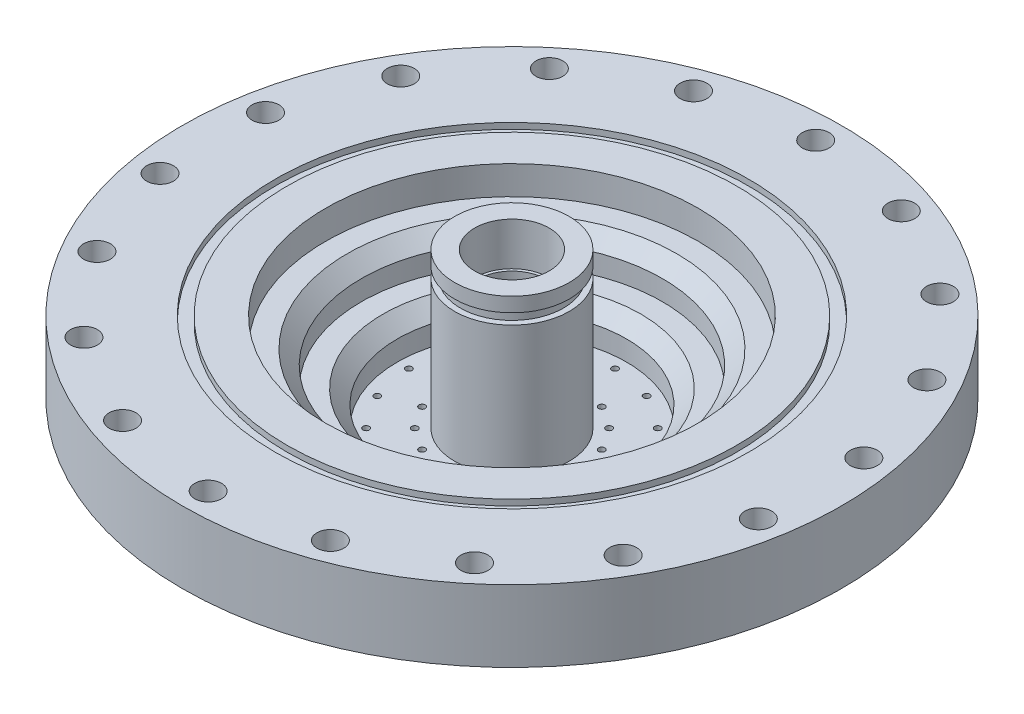
from build123d import *

# Parameters (mm, degrees)
SKETCH1_R           = 38.1
BOSS_EXTRUDE1_DEPTH = 4.445
SKETCH2_R           = 28.575
SKETCH2_R_2         = 7.62
BOSS_EXTRUDE2_DEPTH = 5.08
SKETCH4_R           = 38.1
SKETCH4_R_2         = 7.62
BOSS_EXTRUDE3_DEPTH = 25.4
SKETCH5_R           = 73.025
SKETCH5_R_2         = 38.1
BOSS_EXTRUDE4_DEPTH = 19.05
SKETCH6_R           = 41.275
SKETCH6_R_2         = 12.7
CUT_EXTRUDE1_DEPTH  = 9.525
SKETCH7_R           = 33.3375
SKETCH7_R_2         = 12.7
CUT_EXTRUDE2_DEPTH  = 7.62
SKETCH8_R           = 25.4
SKETCH8_R_2         = 12.7
CUT_EXTRUDE3_DEPTH  = 7.62
SKETCH10_R          = 12.7
SKETCH10_R_2        = 8.255
BOSS_EXTRUDE5_DEPTH = 9.525
CHAMFER1_SIZE       = 3.175
SKETCH12_R          = 0.6985
CUT_EXTRUDE5_DEPTH  = 10.16
CUT_EXTRUDE6_START  = 8.411991
SKETCH14_R          = 0.508
CUT_EXTRUDE6_DEPTH  = 5.719232
CUT_EXTRUDE7_START  = 8.411991
SKETCH15_R          = 0.508
CUT_EXTRUDE7_DEPTH  = 5.719232
CIRPATTERN2_COUNT   = 16
SKETCH16_W          = 1.27
SKETCH16_H          = 2.3622
SKETCH17_R          = 2.97688
CUT_EXTRUDE8_DEPTH  = 35.925000419
CIRPATTERN3_COUNT   = 18
SKETCH20_R          = 86.430986252
SKETCH20_R_2        = 37.221288793
CUT_EXTRUDE11_DEPTH = 3.175
SKETCH18_R          = 52.4383
SKETCH18_R_2        = 49.7967
CUT_EXTRUDE9_DEPTH  = 1.3208
SKETCH19_R          = 0.79375
CUT_EXTRUDE10_DEPTH = 86.868315867
CIRPATTERN4_COUNT   = 16
SKETCH21_W          = 2.4892
SKETCH21_H          = 2.3622


with BuildPart() as part:
    # Sketch1 → Boss-Extrude1 (new body)
    with BuildSketch(Plane(origin=(0, 0, 0), x_dir=(1, 0, 0), z_dir=(0, 1, 0))):
        Circle(SKETCH1_R)
    extrude(amount=BOSS_EXTRUDE1_DEPTH)

    # Sketch2 → Boss-Extrude2 (add)
    with BuildSketch(Plane(origin=(0, 4.445, 0), x_dir=(1, 0, 0), z_dir=(0, 1, 0))):
        Circle(SKETCH2_R)
        Circle(SKETCH2_R_2, mode=Mode.SUBTRACT)
    extrude(amount=BOSS_EXTRUDE2_DEPTH)

    # Sketch4 → Boss-Extrude3 (add)
    with BuildSketch(Plane(origin=(0, 9.525, 0), x_dir=(1, 0, 0), z_dir=(0, 1, 0))):
        Circle(SKETCH4_R)
        Circle(SKETCH4_R_2, mode=Mode.SUBTRACT)
    extrude(amount=BOSS_EXTRUDE3_DEPTH)

    # Sketch5 → Boss-Extrude4 (add)
    with BuildSketch(Plane(origin=(0, 34.925, 0), x_dir=(1, 0, 0), z_dir=(0, 1, 0))):
        Circle(SKETCH5_R)
        Circle(SKETCH5_R_2, mode=Mode.SUBTRACT)
    extrude(amount=-BOSS_EXTRUDE4_DEPTH)

    # Sketch6 → Cut-Extrude1 (cut)
    with BuildSketch(Plane(origin=(0, 34.925, 0), x_dir=(1, 0, 0), z_dir=(0, 1, 0))):
        Circle(SKETCH6_R)
        Circle(SKETCH6_R_2, mode=Mode.SUBTRACT)
    extrude(amount=-CUT_EXTRUDE1_DEPTH, mode=Mode.SUBTRACT)

    # Sketch7 → Cut-Extrude2 (cut)
    with BuildSketch(Plane(origin=(0, 25.4, 0), x_dir=(1, 0, 0), z_dir=(0, 1, 0))):
        Circle(SKETCH7_R)
        Circle(SKETCH7_R_2, mode=Mode.SUBTRACT)
    extrude(amount=-CUT_EXTRUDE2_DEPTH, mode=Mode.SUBTRACT)

    # Sketch8 → Cut-Extrude3 (cut)
    with BuildSketch(Plane(origin=(0, 17.78, 0), x_dir=(1, 0, 0), z_dir=(0, 1, 0))):
        Circle(SKETCH8_R)
        Circle(SKETCH8_R_2, mode=Mode.SUBTRACT)
    extrude(amount=-CUT_EXTRUDE3_DEPTH, mode=Mode.SUBTRACT)

    # Sketch10 → Boss-Extrude5 (add)
    with BuildSketch(Plane(origin=(0, 34.925, 0), x_dir=(1, 0, 0), z_dir=(0, 1, 0))):
        Circle(SKETCH10_R)
        Circle(SKETCH10_R_2, mode=Mode.SUBTRACT)
    extrude(amount=BOSS_EXTRUDE5_DEPTH)

    # Chamfer1
    chamfer1_edges = [part.edges().sort_by_distance(p)[0] for p in [
        (-33.3375, 25.4, 0),
        (-25.4, 17.78, 0),
    ]]
    chamfer(chamfer1_edges, length=CHAMFER1_SIZE)

    # Sketch12 → Cut-Extrude5 (cut)
    with BuildSketch(Plane.XZ):
        with Locations((5.828207446, 14.070537459)):
            Circle(SKETCH12_R)
        with Locations((8.742311168, 21.105806189)):
            Circle(SKETCH12_R)
    cut_extrude5 = extrude(amount=-CUT_EXTRUDE5_DEPTH, mode=Mode.SUBTRACT)

    # Sketch14 → Cut-Extrude6 (cut)
    with BuildSketch(Plane(origin=(2.394210183, -10.836355406, 5.780134695), x_dir=(-0.331413574, -0.5, -0.800103145), z_dir=(-0.191341716, 0.866025404, -0.461939766)).offset(CUT_EXTRUDE6_START)):
        with Locations((-6.594714168, 0)):
            Circle(SKETCH14_R)
    cut_extrude6 = extrude(amount=CUT_EXTRUDE6_DEPTH, mode=Mode.SUBTRACT)

    # Sketch15 → Cut-Extrude7 (cut)
    with BuildSketch(Plane(origin=(1.24841947, 5.650430014, 3.013951217), x_dir=(-0.331413574, 0.5, -0.800103145), z_dir=(0.191341716, 0.866025404, 0.461939766)).offset(CUT_EXTRUDE7_START)):
        with Locations((-26.378856671, 0)):
            Circle(SKETCH15_R)
    cut_extrude7 = extrude(amount=CUT_EXTRUDE7_DEPTH, mode=Mode.SUBTRACT)

    # CirPattern2: Cut-Extrude5, Cut-Extrude6, Cut-Extrude7 ×16 about axis
    cirpattern2_axis = Axis((0, 0, 0), (0, 1, 0))
    for i in range(1, CIRPATTERN2_COUNT):
        add(cut_extrude5.rotate(cirpattern2_axis, i * 360 / CIRPATTERN2_COUNT), mode=Mode.SUBTRACT)
        add(cut_extrude6.rotate(cirpattern2_axis, i * 360 / CIRPATTERN2_COUNT), mode=Mode.SUBTRACT)
        add(cut_extrude7.rotate(cirpattern2_axis, i * 360 / CIRPATTERN2_COUNT), mode=Mode.SUBTRACT)

    # Sketch16 → Cut-Revolve2 (revolve, cut)
    with BuildSketch(Plane.XY):
        with Locations((-12.065, 40.0939)):
            Rectangle(SKETCH16_W, SKETCH16_H)
    revolve(axis=Axis((0, 0, 0), (0, 1, 0)), mode=Mode.SUBTRACT)

    # Sketch17 → Cut-Extrude8 (cut, through all)
    with BuildSketch(Plane(origin=(0, 34.925, 0), x_dir=(1, 0, 0), z_dir=(0, 1, 0))):
        with Locations((0, 67.31)):
            Circle(SKETCH17_R)
    cut_extrude8 = extrude(amount=-CUT_EXTRUDE8_DEPTH, mode=Mode.SUBTRACT)

    # CirPattern3: Cut-Extrude8 ×18 about axis
    cirpattern3_axis = Axis((0, 0, 0), (0, 1, 0))
    for i in range(1, CIRPATTERN3_COUNT):
        add(cut_extrude8.rotate(cirpattern3_axis, i * 360 / CIRPATTERN3_COUNT), mode=Mode.SUBTRACT)

    # Sketch20 → Cut-Extrude11 (cut)
    with BuildSketch(Plane(origin=(0, 34.925, 0), x_dir=(1, 0, 0), z_dir=(0, 1, 0))):
        Circle(SKETCH20_R)
        Circle(SKETCH20_R_2, mode=Mode.SUBTRACT)
    extrude(amount=-CUT_EXTRUDE11_DEPTH, mode=Mode.SUBTRACT)

    # Sketch18 → Cut-Extrude9 (cut)
    with BuildSketch(Plane(origin=(0, 31.75, 0), x_dir=(1, 0, 0), z_dir=(0, 1, 0))):
        Circle(SKETCH18_R)
        Circle(SKETCH18_R_2, mode=Mode.SUBTRACT)
    extrude(amount=-CUT_EXTRUDE9_DEPTH, mode=Mode.SUBTRACT)

    # Sketch19 → Cut-Extrude10 (cut, through all)
    with BuildSketch(Plane(origin=(0, 0, 0), x_dir=(0, 1, 0), z_dir=(0.98078528, 0, -0.195090322))):
        with Locations((6.35, 0)):
            Circle(SKETCH19_R)
    cut_extrude10 = extrude(amount=-CUT_EXTRUDE10_DEPTH, mode=Mode.SUBTRACT)

    # CirPattern4: Cut-Extrude10 ×16 about axis
    cirpattern4_axis = Axis((0, 15.875, 0), (0, 1, 0))
    for i in range(1, CIRPATTERN4_COUNT):
        add(cut_extrude10.rotate(cirpattern4_axis, i * 360 / CIRPATTERN4_COUNT), mode=Mode.SUBTRACT)

    # Sketch21 → Cut-Revolve3 (revolve, cut)
    with BuildSketch(Plane.XY):
        with Locations((38.0746, 2.2225)):
            Rectangle(SKETCH21_W, SKETCH21_H)
    revolve(axis=Axis((0, 0, 0), (0, 1, 0)), mode=Mode.SUBTRACT)


solid = part.part
